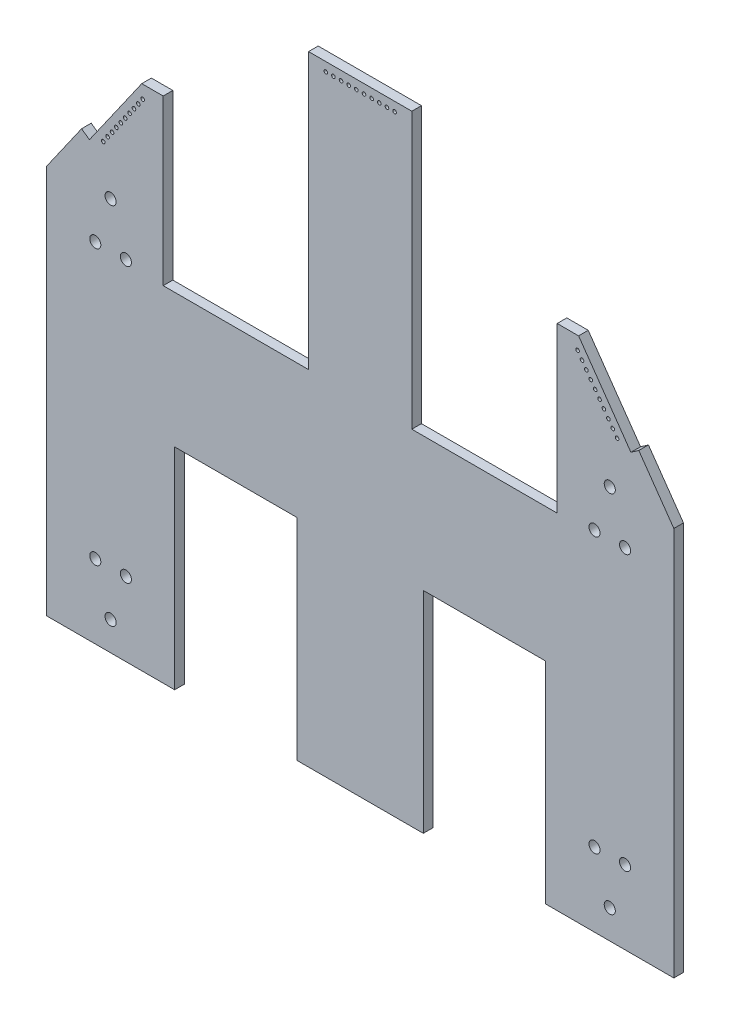
from build123d import *

# Parameters (mm, degrees)
BOSS_EXTRUDE1_DEPTH = 1.6
SKETCH3_R           = 0.92075
CUT_EXTRUDE1_DEPTH  = 2.54
SKETCH4_R           = 0.3
SKETCH4_R_2         = 0.300000035
CUT_EXTRUDE2_DEPTH  = 2.54


with BuildPart() as part:
    # Sketch1 → Boss-Extrude1 (new body)
    with BuildSketch(Plane.XY):
        Polygon((-19.3675, 84.416506551), (-15.810445706, 84.416506551), (-7.127679781, 72.016231702), (-5.81703651, 72.933954), (0, 64.626364903), (0, 0), (-21.2725, 0), (-21.2725, 34.925), (-41.5925, 34.925), (-41.5925, 0), (-62.54750001, 0), (-62.54750001, 34.925), (-82.86750001, 34.925), (-82.86750001, 0), (-104.14000001, 0), (-104.14000001, 64.626364903), (-98.3229635, 72.933954), (-97.01232023, 72.016231702), (-88.329554304, 84.416506551), (-84.77250001, 84.416506551), (-84.77250001, 57.15), (-60.6425, 57.15), (-60.6425, 102.87), (-43.49750001, 102.87), (-43.49750001, 57.15), (-19.3675, 57.15), align=None)
    extrude(amount=BOSS_EXTRUDE1_DEPTH)

    # Sketch3 → Cut-Extrude1 (cut)
    with BuildSketch(Plane.XY.offset(1.6)):
        with Locations((-93.50375001, 4.789717726)):
            Circle(SKETCH3_R)
        with Locations((-90.96375001, 12.257317726)):
            Circle(SKETCH3_R)
        with Locations((-90.96375001, 57.822682274)):
            Circle(SKETCH3_R)
        with Locations((-96.04375001, 12.257317726)):
            Circle(SKETCH3_R)
        with Locations((-93.50375001, 65.290282274)):
            Circle(SKETCH3_R)
        with Locations((-96.04375001, 57.822682274)):
            Circle(SKETCH3_R)
        with Locations((-10.63625, 4.789717726)):
            Circle(SKETCH3_R)
        with Locations((-8.09625, 12.257317726)):
            Circle(SKETCH3_R)
        with Locations((-13.17625, 12.257317726)):
            Circle(SKETCH3_R)
        with Locations((-8.09625, 57.822682274)):
            Circle(SKETCH3_R)
        with Locations((-10.63625, 65.290282274)):
            Circle(SKETCH3_R)
        with Locations((-13.17625, 57.822682274)):
            Circle(SKETCH3_R)
    extrude(amount=-CUT_EXTRUDE1_DEPTH, mode=Mode.SUBTRACT)

    # Sketch4 → Cut-Extrude2 (cut)
    with BuildSketch(Plane(origin=(0, 0, 0), x_dir=(-1, 0, 0), z_dir=(0, 0, -1))):
        with Locations((46.355000005, 101.37)):
            Circle(SKETCH4_R)
        with Locations((47.625000005, 101.37)):
            Circle(SKETCH4_R)
        with Locations((48.895000005, 101.37)):
            Circle(SKETCH4_R)
        with Locations((50.165000005, 101.37)):
            Circle(SKETCH4_R)
        with Locations((51.435000005, 101.37)):
            Circle(SKETCH4_R)
        with Locations((52.705000005, 101.37)):
            Circle(SKETCH4_R)
        with Locations((53.975000005, 101.37)):
            Circle(SKETCH4_R)
        with Locations((55.245000005, 101.37)):
            Circle(SKETCH4_R)
        with Locations((56.515000005, 101.37)):
            Circle(SKETCH4_R)
        with Locations((57.785000005, 101.37)):
            Circle(SKETCH4_R)
        with Locations((88.166138487, 82.256136075)):
            Circle(SKETCH4_R_2)
        with Locations((88.894580561, 81.215812979)):
            Circle(SKETCH4_R_2)
        with Locations((89.623022635, 80.175489883)):
            Circle(SKETCH4_R_2)
        with Locations((90.351464709, 79.135166786)):
            Circle(SKETCH4_R_2)
        with Locations((91.079906783, 78.09484369)):
            Circle(SKETCH4_R_2)
        with Locations((91.808348857, 77.054520594)):
            Circle(SKETCH4_R_2)
        with Locations((92.536790932, 76.014197498)):
            Circle(SKETCH4_R_2)
        with Locations((93.265233006, 74.973874401)):
            Circle(SKETCH4_R_2)
        with Locations((93.99367508, 73.933551305)):
            Circle(SKETCH4_R_2)
        with Locations((94.722117154, 72.893228209)):
            Circle(SKETCH4_R_2)
        with Locations((9.417882856, 72.893228209)):
            Circle(SKETCH4_R_2)
        with Locations((10.14632493, 73.933551305)):
            Circle(SKETCH4_R_2)
        with Locations((10.874767005, 74.973874401)):
            Circle(SKETCH4_R_2)
        with Locations((11.603209079, 76.014197498)):
            Circle(SKETCH4_R_2)
        with Locations((12.331651153, 77.054520594)):
            Circle(SKETCH4_R_2)
        with Locations((13.060093227, 78.09484369)):
            Circle(SKETCH4_R_2)
        with Locations((13.788535301, 79.135166786)):
            Circle(SKETCH4_R_2)
        with Locations((14.516977375, 80.175489883)):
            Circle(SKETCH4_R_2)
        with Locations((15.24541945, 81.215812979)):
            Circle(SKETCH4_R_2)
        with Locations((15.973861524, 82.256136075)):
            Circle(SKETCH4_R_2)
    extrude(amount=-CUT_EXTRUDE2_DEPTH, mode=Mode.SUBTRACT)


solid = part.part
